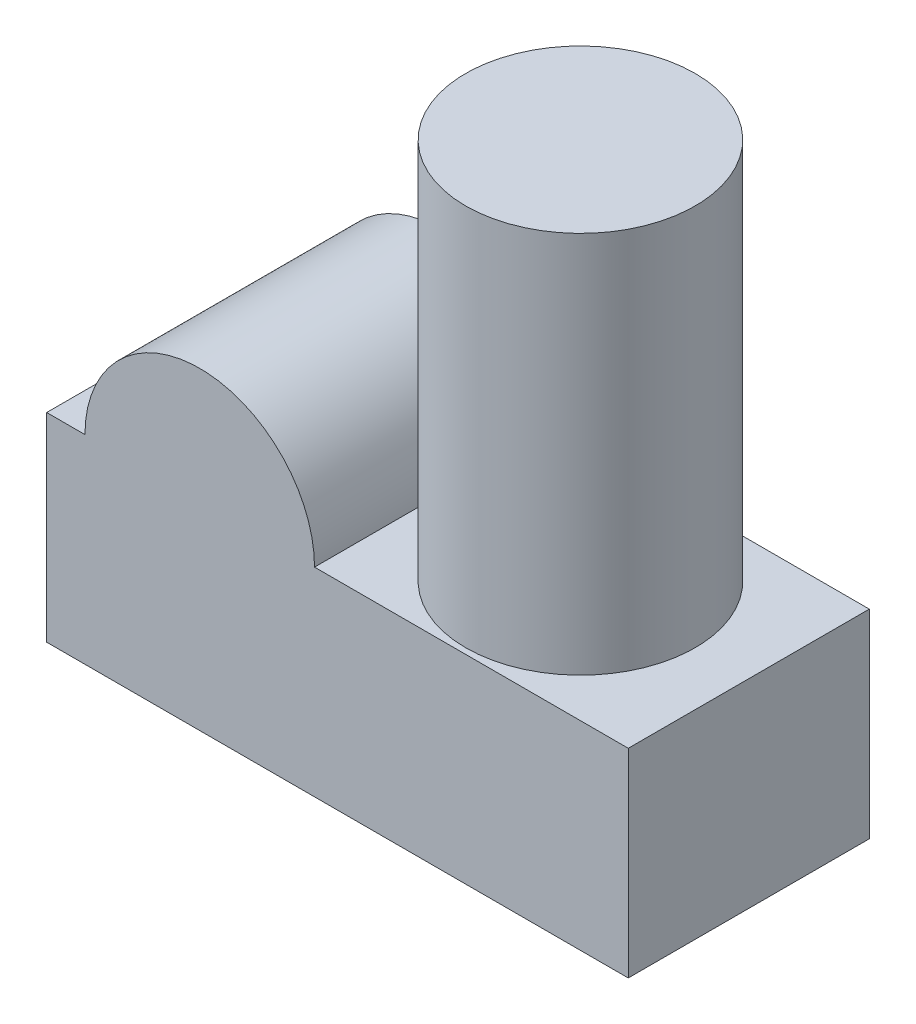
from build123d import *

# Parameters (mm, degrees)
BOSS_EXTRU_1_DEPTH = 31.5
ESQUISSE2_R        = 15
BOSS_EXTRU_2_DEPTH = 50


with BuildPart() as part:
    # Esquisse1 → Boss.-Extru.1 (new body)
    with BuildSketch(Plane.XY):
        with BuildLine():
            Line((35, 26), (76, 26))
            Line((76, 26), (76, 0))
            Line((76, 0), (0, 0))
            Line((0, 0), (0, 26))
            Line((0, 26), (5, 26))
            ThreePointArc((5, 26), (20, 41), (35, 26))
        make_face()
    extrude(amount=BOSS_EXTRU_1_DEPTH)

    # Esquisse2 → Boss.-Extru.2 (add)
    with BuildSketch(Plane(origin=(0, 26, 0), x_dir=(1, 0, 0), z_dir=(0, 1, 0))):
        with Locations((54, -15.75)):
            Circle(ESQUISSE2_R)
    extrude(amount=BOSS_EXTRU_2_DEPTH)


solid = part.part
